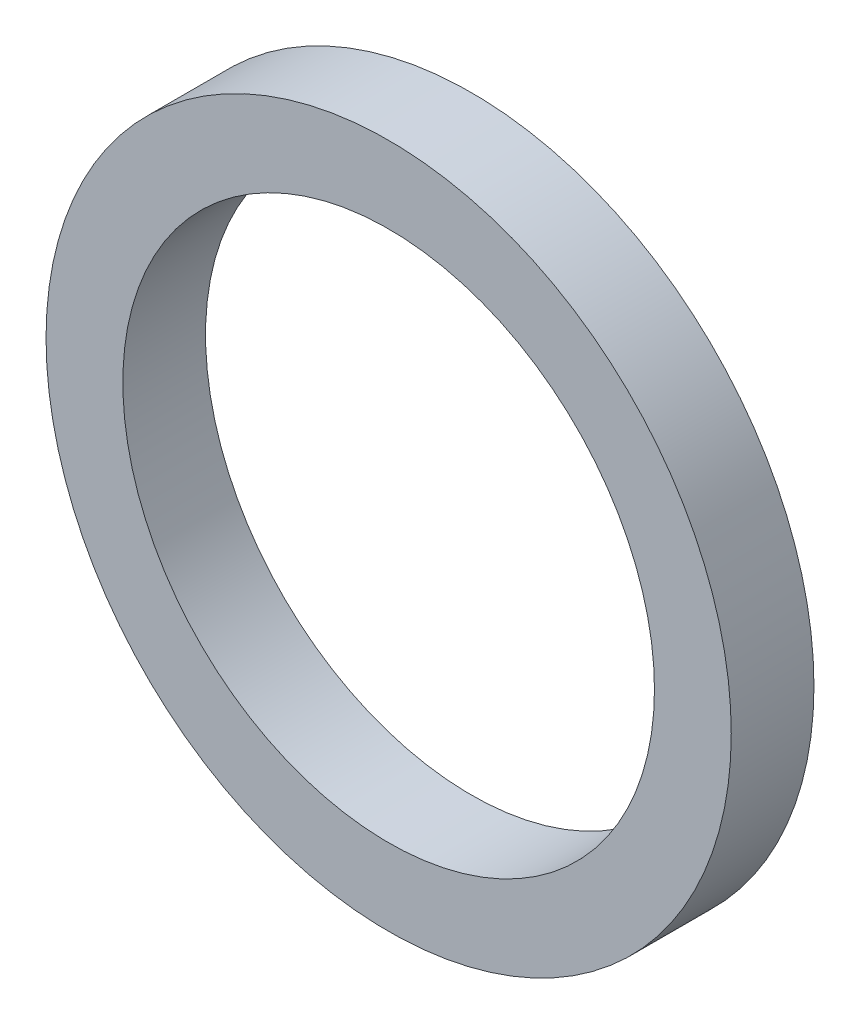
from build123d import *

# Parameters (mm, degrees)
SKETCH_1_R      = 29
SKETCH_1_R_2    = 22.5
EXTRUDE_1_DEPTH = 7
SHELL_1_T       = -1


with BuildPart() as part:
    # 草图1 → 凸台-拉伸1 (new body)
    with BuildSketch(Plane.XY):
        Circle(SKETCH_1_R)
        Circle(SKETCH_1_R_2, mode=Mode.SUBTRACT)
    extrude(amount=EXTRUDE_1_DEPTH)

    # 抽壳1
    shell_1_openings = [part.faces().sort_by_distance(p)[0] for p in [
        (-28.179756134, 0, 0),
    ]]
    offset(amount=SHELL_1_T, openings=shell_1_openings, kind=Kind.INTERSECTION)


solid = part.part
